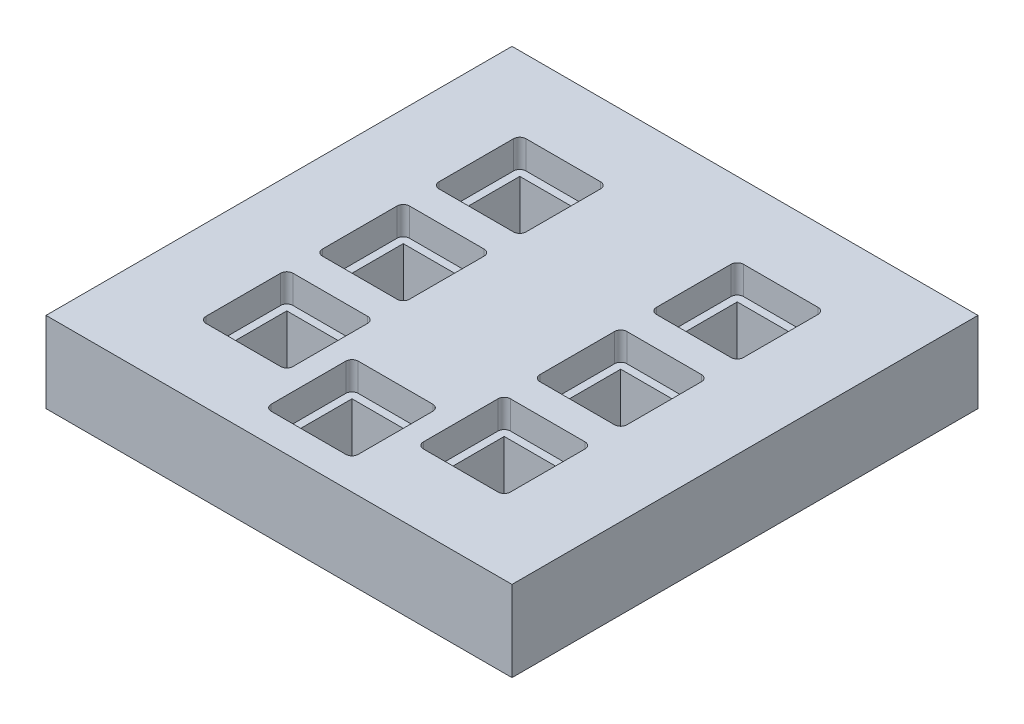
from build123d import *

# Parameters (mm, degrees)
SKETCH1_W           = 150
SKETCH1_H           = 150
BOSS_EXTRUDE1_DEPTH = 26
CUT_EXTRUDE1_DEPTH  = 9
SKETCH3_W           = 23
SKETCH3_H           = 23
CUT_EXTRUDE2_DEPTH  = 18


with BuildPart() as part:
    # Sketch1 → Boss-Extrude1 (new body)
    with BuildSketch(Plane(origin=(0, 0, 0), x_dir=(1, 0, 0), z_dir=(0, 1, 0))):
        Rectangle(SKETCH1_W, SKETCH1_H)
    extrude(amount=BOSS_EXTRUDE1_DEPTH)

    # Sketch2 → Cut-Extrude1 (cut)
    with BuildSketch(Plane(origin=(0, 26, 0), x_dir=(1, 0, 0), z_dir=(0, 1, 0))):
        with BuildLine():
            Line((-47, 23.5), (-23, 23.5))
            ThreePointArc((-23, 23.5), (-21.585786438, 24.085786438), (-21, 25.5))
            Line((-21, 25.5), (-21, 49.5))
            ThreePointArc((-21, 49.5), (-21.585786438, 50.914213562), (-23, 51.5))
            Line((-23, 51.5), (-47, 51.5))
            ThreePointArc((-47, 51.5), (-48.414213562, 50.914213562), (-49, 49.5))
            Line((-49, 49.5), (-49, 25.5))
            ThreePointArc((-49, 25.5), (-48.414213562, 24.085786438), (-47, 23.5))
        make_face()
        with BuildLine():
            Line((-47, 14), (-23, 14))
            ThreePointArc((-23, 14), (-21.585786438, 13.414213562), (-21, 12))
            Line((-21, 12), (-21, -12))
            ThreePointArc((-21, -12), (-21.585786438, -13.414213562), (-23, -14))
            Line((-23, -14), (-47, -14))
            ThreePointArc((-47, -14), (-48.414213562, -13.414213562), (-49, -12))
            Line((-49, -12), (-49, 12))
            ThreePointArc((-49, 12), (-48.414213562, 13.414213562), (-47, 14))
        make_face()
        with BuildLine():
            Line((-21, -49.5), (-21, -25.5))
            ThreePointArc((-21, -25.5), (-21.585786438, -24.085786438), (-23, -23.5))
            Line((-23, -23.5), (-47, -23.5))
            ThreePointArc((-47, -23.5), (-48.414213562, -24.085786438), (-49, -25.5))
            Line((-49, -25.5), (-49, -49.5))
            ThreePointArc((-49, -49.5), (-48.414213562, -50.914213562), (-47, -51.5))
            Line((-47, -51.5), (-23, -51.5))
            ThreePointArc((-23, -51.5), (-21.585786438, -50.914213562), (-21, -49.5))
        make_face()
        with BuildLine():
            Line((47, -23.5), (23, -23.5))
            ThreePointArc((23, -23.5), (21.585786438, -24.085786438), (21, -25.5))
            Line((21, -25.5), (21, -49.5))
            ThreePointArc((21, -49.5), (21.585786438, -50.914213562), (23, -51.5))
            Line((23, -51.5), (47, -51.5))
            ThreePointArc((47, -51.5), (48.414213562, -50.914213562), (49, -49.5))
            Line((49, -49.5), (49, -25.5))
            ThreePointArc((49, -25.5), (48.414213562, -24.085786438), (47, -23.5))
        make_face()
        with BuildLine():
            Line((21, 49.5), (21, 25.5))
            ThreePointArc((21, 25.5), (21.585786438, 24.085786438), (23, 23.5))
            Line((23, 23.5), (47, 23.5))
            ThreePointArc((47, 23.5), (48.414213562, 24.085786438), (49, 25.5))
            Line((49, 25.5), (49, 49.5))
            ThreePointArc((49, 49.5), (48.414213562, 50.914213562), (47, 51.5))
            Line((47, 51.5), (23, 51.5))
            ThreePointArc((23, 51.5), (21.585786438, 50.914213562), (21, 49.5))
        make_face()
        with BuildLine():
            Line((21, 12), (21, -12))
            ThreePointArc((21, -12), (21.585786438, -13.414213562), (23, -14))
            Line((23, -14), (47, -14))
            ThreePointArc((47, -14), (48.414213562, -13.414213562), (49, -12))
            Line((49, -12), (49, 12))
            ThreePointArc((49, 12), (48.414213562, 13.414213562), (47, 14))
            Line((47, 14), (23, 14))
            ThreePointArc((23, 14), (21.585786438, 13.414213562), (21, 12))
        make_face()
        with BuildLine():
            Line((-12, -37.5), (12, -37.5))
            ThreePointArc((12, -37.5), (13.414213562, -38.085786438), (14, -39.5))
            Line((14, -39.5), (14, -63.5))
            ThreePointArc((14, -63.5), (13.414213562, -64.914213562), (12, -65.5))
            Line((12, -65.5), (-12, -65.5))
            ThreePointArc((-12, -65.5), (-13.414213562, -64.914213562), (-14, -63.5))
            Line((-14, -63.5), (-14, -39.5))
            ThreePointArc((-14, -39.5), (-13.414213562, -38.085786438), (-12, -37.5))
        make_face()
    extrude(amount=-CUT_EXTRUDE1_DEPTH, mode=Mode.SUBTRACT)

    # Sketch3 → Cut-Extrude2 (cut, through all)
    with BuildSketch(Plane(origin=(0, 17, 0), x_dir=(1, 0, 0), z_dir=(0, 1, 0))):
        with Locations((-35, -37.5)):
            Rectangle(SKETCH3_W, SKETCH3_H)
        with Locations((-35, 37.5)):
            Rectangle(SKETCH3_W, SKETCH3_H)
        with Locations((35, -37.5)):
            Rectangle(SKETCH3_W, SKETCH3_H)
        with Locations((35, 37.5)):
            Rectangle(SKETCH3_W, SKETCH3_H)
        with Locations((-35, 0)):
            Rectangle(SKETCH3_W, SKETCH3_H)
        with Locations((35, 0)):
            Rectangle(SKETCH3_W, SKETCH3_H)
        with Locations((0, -51.5)):
            Rectangle(SKETCH3_W, SKETCH3_H)
    extrude(amount=-CUT_EXTRUDE2_DEPTH, mode=Mode.SUBTRACT)


solid = part.part
